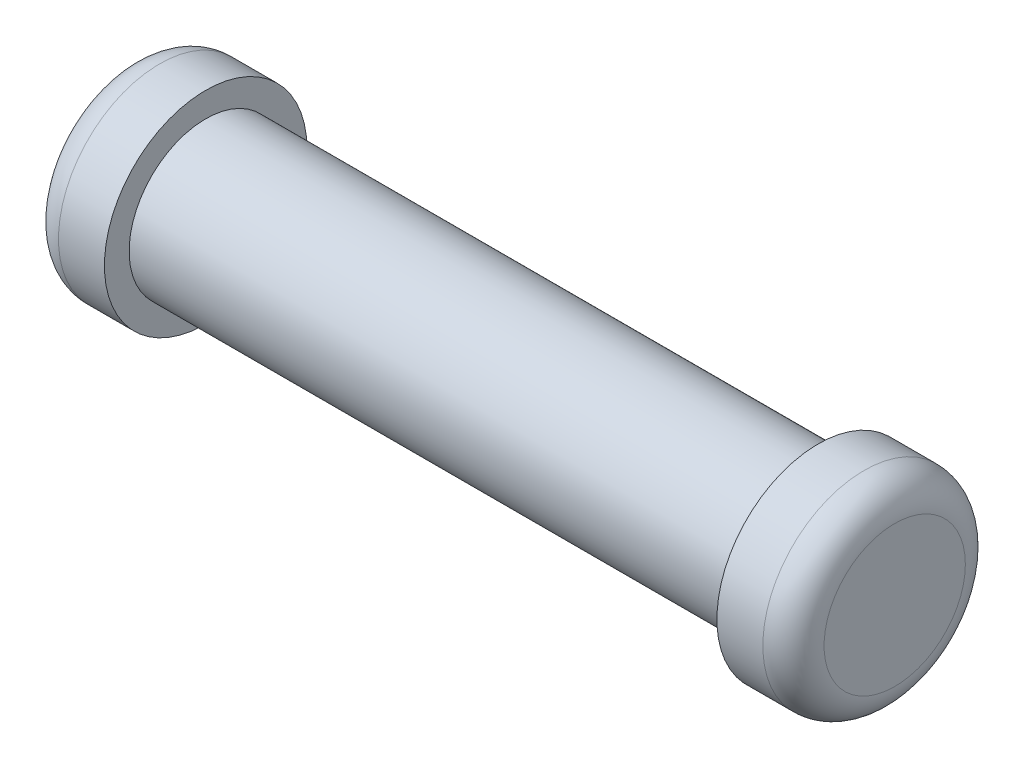
from build123d import *


with BuildPart() as part:
    # Sketch1 → Revolve1 (revolve)
    with BuildSketch(Plane(origin=(0, 0, 0), x_dir=(1, 0, 0), z_dir=(0, 1, 0))):
        with BuildLine():
            Line((-100.780645161, -25.4), (102.419354839, -25.4))
            Line((102.419354839, -25.4), (102.419354839, -33.593548387))
            Line((102.419354839, -33.593548387), (117.659354839, -33.593548387))
            ThreePointArc((117.659354839, -33.593548387), (124.843559736, -30.617753284), (127.819354839, -23.433548387))
            Line((127.819354839, -23.433548387), (127.819354839, 0))
            Line((127.819354839, 0), (-126.180645161, 0))
            Line((-126.180645161, 0), (-126.180645161, -23.433548387))
            ThreePointArc((-126.180645161, -23.433548387), (-123.204850058, -30.617753284), (-116.020645161, -33.593548387))
            Line((-116.020645161, -33.593548387), (-100.780645161, -33.593548387))
            Line((-100.780645161, -33.593548387), (-100.780645161, -25.4))
        make_face()
    revolve(axis=Axis((127.819354839, 0, 0), (-1, 0, 0)))


solid = part.part
